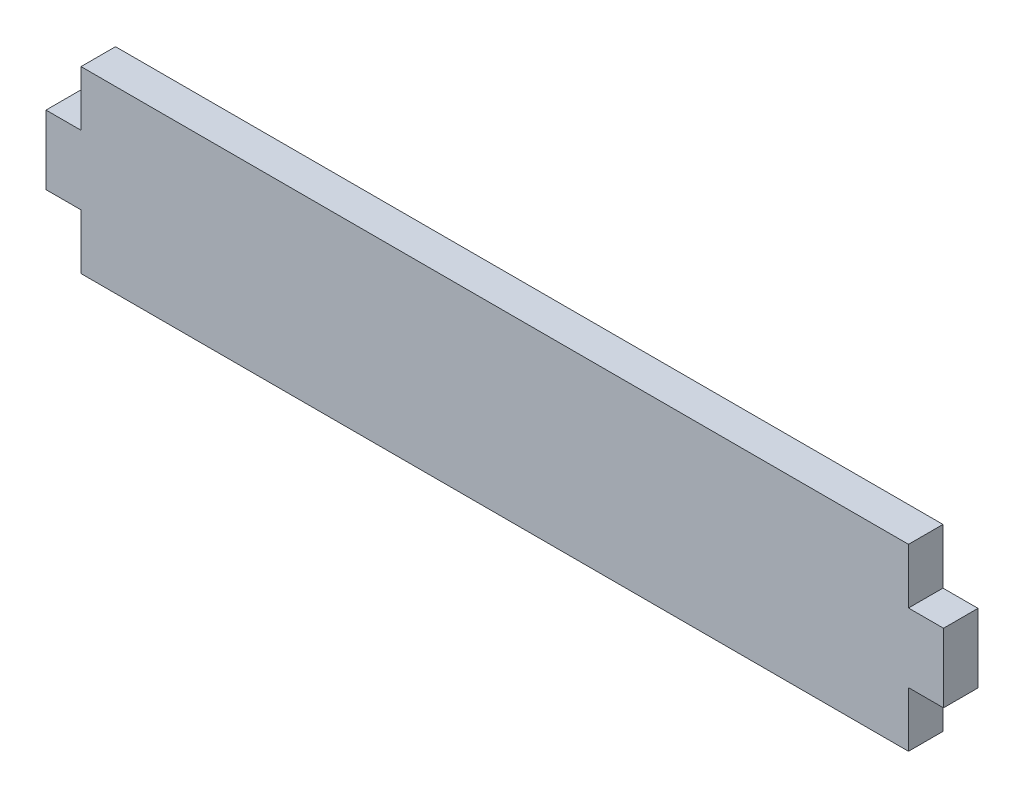
from build123d import *

# Parameters (mm, degrees)
SKETCH1_W           = 76.2
SKETCH1_H           = 16.51
BOSS_EXTRUDE1_DEPTH = 3.175
BOSS_EXTRUDE2_DEPTH = 3.175


with BuildPart() as part:
    # Sketch1 → Boss-Extrude1 (new body)
    with BuildSketch(Plane.XY):
        Rectangle(SKETCH1_W, SKETCH1_H)
    extrude(amount=BOSS_EXTRUDE1_DEPTH)

    # Sketch3 → Boss-Extrude2 (add)
    with BuildSketch(Plane.XY.offset(3.175)):
        Polygon((-38.1, 0), (-38.1, 3.175), (-41.3258, 3.175), (-41.3258, -3.175), (-38.1, -3.175), align=None)
    boss_extrude2 = extrude(amount=-BOSS_EXTRUDE2_DEPTH)

    # Mirror2: Boss-Extrude2 across plane
    add(boss_extrude2.mirror(Plane(origin=(0, 0, 0), x_dir=(0, 0, 1), z_dir=(1, 0, 0))))


solid = part.part
